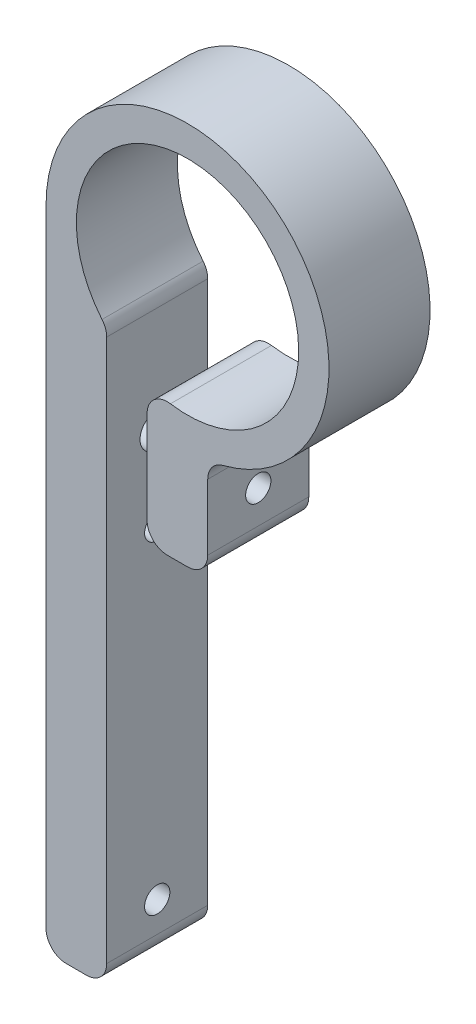
from build123d import *

# Parameters (mm, degrees)
EXTRUDE_1_DEPTH             = 10
FILLET_1_R                  = 2
HOLE_WIZARD_M31_D           = 3.4
HOLE_WIZARD_M31_DEPTH       = 6
HOLE_WIZARD_M31_CBORE_D     = 6.5
HOLE_WIZARD_M31_CBORE_DEPTH = 3
M3X0_51_D                   = 2.5
M3X0_51_DEPTH               = 6
M3X0_52_D                   = 2.5


with BuildPart() as part:
    # Эскиз1 → Бобышка-Вытянуть1 (new body)
    with BuildSketch(Plane.XY):
        with BuildLine():
            Line((-14, 0), (-14, -64))
            Line((-14, -64), (-8, -64))
            Line((-8, -64), (-8, -7.549834435))
            ThreePointArc((-8, -7.549834435), (6.149683661, 9.120383264), (-4, -10.246950766))
            Line((-4, -10.246950766), (-4, -24))
            Line((-4, -24), (2, -24))
            Line((2, -24), (2, -13.856406461))
            ThreePointArc((2, -13.856406461), (9.16515139, 10.583005244), (-14, 0))
        make_face()
    extrude(amount=EXTRUDE_1_DEPTH)

    # Скругление1
    fillet_1_edges = [part.edges().sort_by_distance(p)[0] for p in [
        (2, -13.856406461, 5),
        (2, -24, 5),
        (-4, -24, 5),
        (-4, -10.246950766, 5),
        (-8, -7.549834435, 5),
        (-8, -64, 5),
        (-14, -64, 5),
    ]]
    fillet(fillet_1_edges, radius=FILLET_1_R)

    # Цековка для винта с внутренним шестигранником M31
    with Locations(Plane.ZY.offset(14)):
        with Locations((5, -18.745966692)):
            CounterBoreHole(HOLE_WIZARD_M31_D / 2, HOLE_WIZARD_M31_CBORE_D / 2, HOLE_WIZARD_M31_CBORE_DEPTH, depth=HOLE_WIZARD_M31_DEPTH)

    # Отверстие обработанное метчиком M3x0.51
    with Locations(Plane.ZY.offset(4)):
        with Locations((5, -18.745966692)):
            Hole(M3X0_51_D / 2, depth=M3X0_51_DEPTH)

    # Отверстие обработанное метчиком M3x0.52 (through all)
    with Locations(Plane.ZY.offset(14)):
        with Locations((5, -27), (5, -59)):
            Hole(M3X0_52_D / 2)


solid = part.part
